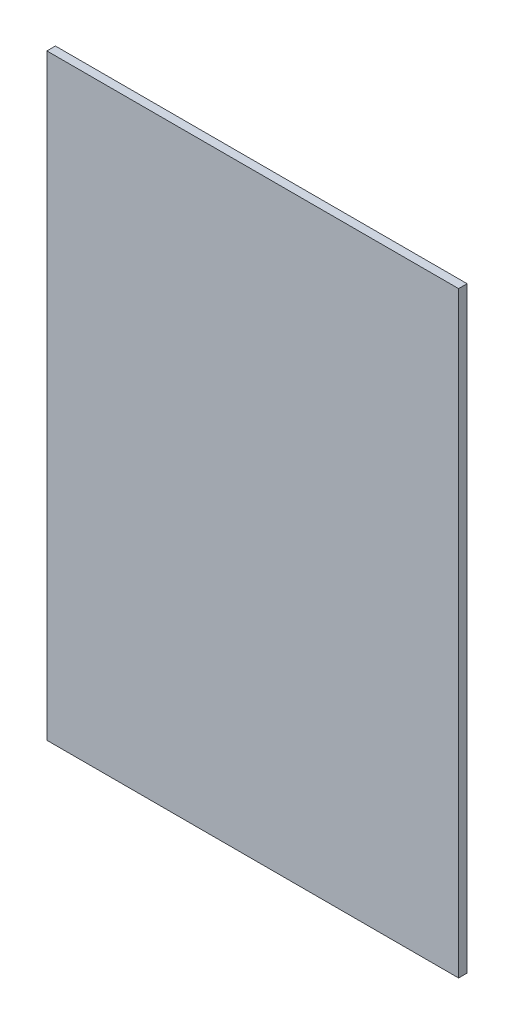
from build123d import *

# Parameters (mm, degrees)
SKETCH1_W           = 967.132740307
SKETCH1_H           = 1402.535129369
BOSS_EXTRUDE1_DEPTH = 20


with BuildPart() as part:
    # Sketch1 → Boss-Extrude1 (new body)
    with BuildSketch(Plane.XY):
        with Locations((12034.832609318, 9007.348735233)):
            Rectangle(SKETCH1_W, SKETCH1_H)
    extrude(amount=BOSS_EXTRUDE1_DEPTH)


solid = part.part
